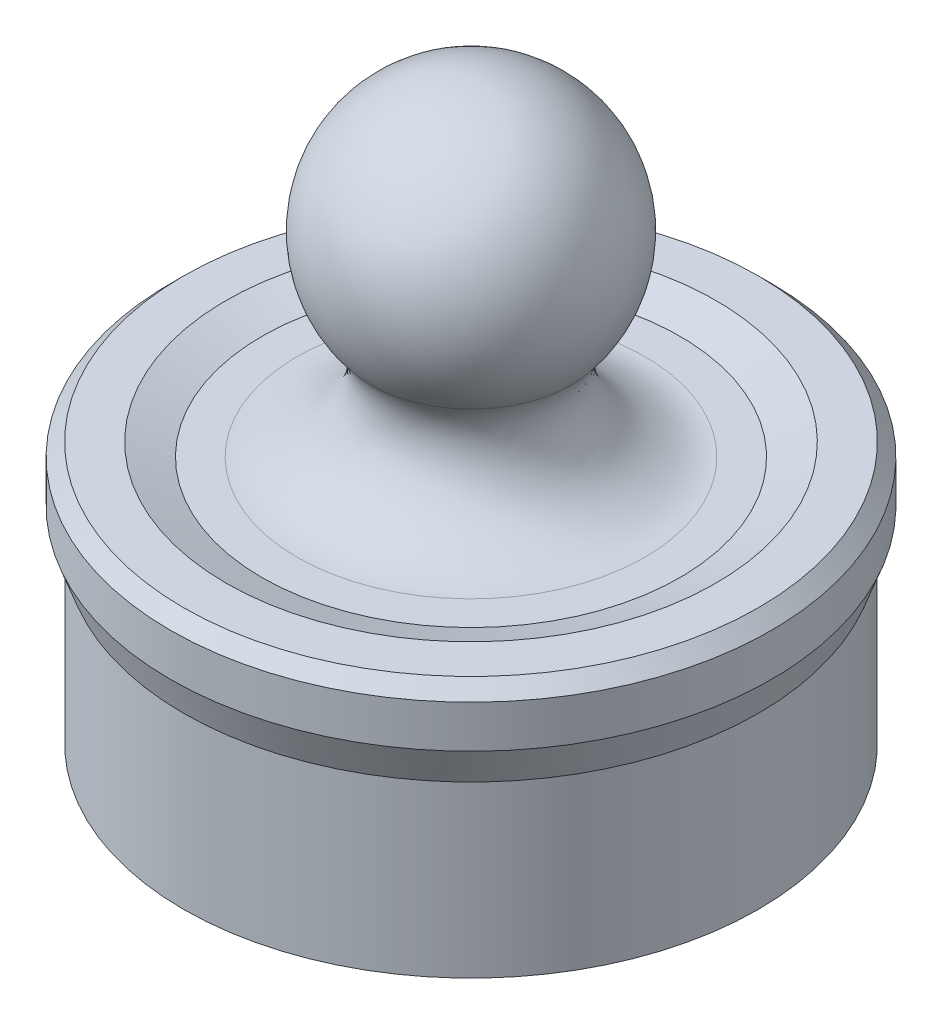
from build123d import *


with BuildPart() as part:
    # Sketch1 → Revolve2 (revolve)
    with BuildSketch(Plane.XY):
        with BuildLine():
            Line((-9, -7.5), (-9, 0))
            Line((-9, 0), (0, 0))
            Line((0, 0), (0, 2))
            Line((0, 2), (0, 14.5))
            ThreePointArc((0, 14.5), (-4.526641021, 11.623563296), (-3.845043489, 6.303808428))
            add(Edge.make_bspline(
                [(-6.655258628, 2), (-6.120506519, 2), (-5.250490252, 2.299992699), (-3.576908903, 3.35585887), (-2.957362509, 5.235921257), (-3.845043489, 6.303808428)],
                knots=[0, 0, 0, 0, 0.245004217, 0.484762515, 1, 1, 1, 1], degree=3))
            Line((-6.655258628, 2), (-8, 2))
            Line((-8, 2), (-9.37373871, 2.5))
            Line((-9.37373871, 2.5), (-11, 2.5))
            Line((-11, 2.5), (-11.5, 2))
            Line((-11.5, 2), (-11.5, 0.37373871))
            Line((-11.5, 0.37373871), (-11, -1))
            Line((-11, -1), (-11, -7.5))
            Line((-11, -7.5), (-9, -7.5))
        make_face()
    revolve(axis=Axis((0, 14.5, 0), (0, -1, 0)))


solid = part.part
